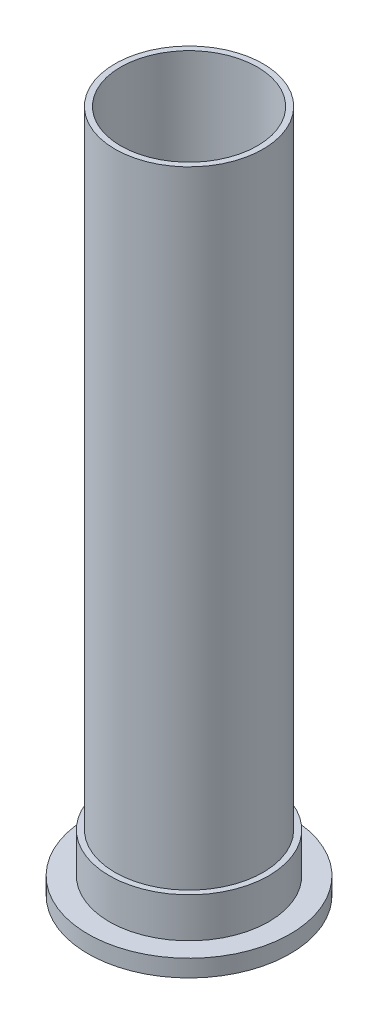
from build123d import *

# Parameters (mm, degrees)
SKETCH2_R               = 41.275
SKETCH2_R_2             = 38.1
BASE_CYLINDER_DEPTH     = 381
SKETCH3_R               = 56.35625
SKETCH3_R_2             = 38.1
AFT_FLANGE_DEPTH        = 9.525
SKETCH34_R              = 39.75
TEMPERATUREINSERT_DEPTH = 28.575
SKETCH33_R              = 44.45
SKETCH33_R_2            = 41.275
CRITICALBOSS_DEPTH      = 22.225


with BuildPart() as part:
    # Sketch2 → Base Cylinder (new body)
    with BuildSketch(Plane(origin=(0, 0, 0), x_dir=(1, 0, 0), z_dir=(0, 1, 0))):
        Circle(SKETCH2_R)
        Circle(SKETCH2_R_2, mode=Mode.SUBTRACT)
    extrude(amount=BASE_CYLINDER_DEPTH)

    # Sketch3 → Aft Flange (add)
    with BuildSketch(Plane.XZ):
        Circle(SKETCH3_R)
        Circle(SKETCH3_R_2, mode=Mode.SUBTRACT)
    extrude(amount=-AFT_FLANGE_DEPTH)

    # Sketch34 → TemperatureInsert (cut)
    with BuildSketch(Plane.XZ):
        Circle(SKETCH34_R)
    extrude(amount=-TEMPERATUREINSERT_DEPTH, mode=Mode.SUBTRACT)

    # Sketch33 → CriticalBoss (add)
    with BuildSketch(Plane(origin=(0, 9.525, 0), x_dir=(1, 0, 0), z_dir=(0, 1, 0))):
        Circle(SKETCH33_R)
        Circle(SKETCH33_R_2, mode=Mode.SUBTRACT)
    extrude(amount=CRITICALBOSS_DEPTH)


solid = part.part
